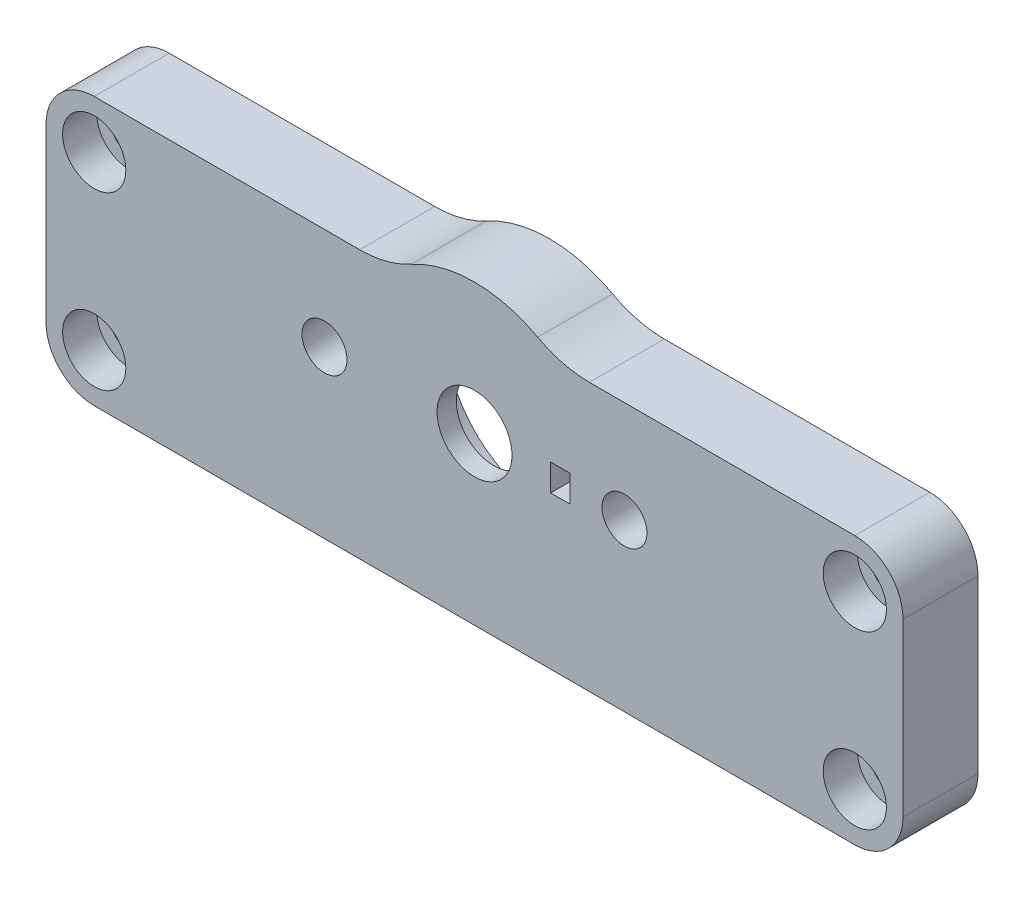
from build123d import *

# Parameters (mm, degrees)
SKETCH1_R           = 9.75
SKETCH1_R_2         = 1.65
BOSS_EXTRUDE1_DEPTH = 7
FILLET1_R           = 10
SKETCH2_R           = 9.75
SKETCH2_R_2         = 7.5
BOSS_EXTRUDE2_DEPTH = 2
SKETCH3_R           = 7.5
SKETCH3_R_2         = 3.5
BOSS_EXTRUDE3_DEPTH = 1.8
SKETCH4_W           = 1.8
SKETCH4_H           = 2.5
CUT_EXTRUDE1_DEPTH  = 2.5
SKETCH5_R           = 2.1
CUT_EXTRUDE2_DEPTH  = 3
SKETCH6_R           = 2.95
CUT_EXTRUDE3_DEPTH  = 3.2


with BuildPart() as part:
    # Sketch1 → Boss-Extrude1 (new body)
    with BuildSketch(Plane.XY):
        with BuildLine():
            Line((-35.5, 9.5), (-7.733854149, 9.5))
            ThreePointArc((-7.733854149, 9.5), (0, 12.25), (7.733854149, 9.5))
            Line((7.733854149, 9.5), (35.5, 9.5))
            ThreePointArc((35.5, 9.5), (38.681980515, 8.181980515), (40, 5))
            Line((40, 5), (40, -11))
            ThreePointArc((40, -11), (38.681980515, -14.181980515), (35.5, -15.5))
            Line((35.5, -15.5), (-35.5, -15.5))
            ThreePointArc((-35.5, -15.5), (-38.681980515, -14.181980515), (-40, -11))
            Line((-40, -11), (-40, 5))
            ThreePointArc((-40, 5), (-38.681980515, 8.181980515), (-35.5, 9.5))
        make_face()
        Circle(SKETCH1_R, mode=Mode.SUBTRACT)
        with Locations((-35.5, 5)):
            Circle(SKETCH1_R_2, mode=Mode.SUBTRACT)
        with Locations((35.5, 5)):
            Circle(SKETCH1_R_2, mode=Mode.SUBTRACT)
        with Locations((-35.5, -11)):
            Circle(SKETCH1_R_2, mode=Mode.SUBTRACT)
        with Locations((35.5, -11)):
            Circle(SKETCH1_R_2, mode=Mode.SUBTRACT)
    extrude(amount=BOSS_EXTRUDE1_DEPTH)

    # Fillet1
    fillet1_edges = [part.edges().sort_by_distance(p)[0] for p in [
        (7.733854149, 9.5, 3.5),
        (-7.733854149, 9.5, 3.5),
    ]]
    fillet(fillet1_edges, radius=FILLET1_R)

    # Sketch2 → Boss-Extrude2 (add)
    with BuildSketch(Plane.XY.offset(7)):
        Circle(SKETCH2_R)
        Circle(SKETCH2_R_2, mode=Mode.SUBTRACT)
    extrude(amount=-BOSS_EXTRUDE2_DEPTH)

    # Sketch3 → Boss-Extrude3 (add)
    with BuildSketch(Plane.XY.offset(7)):
        Circle(SKETCH3_R)
        Circle(SKETCH3_R_2, mode=Mode.SUBTRACT)
    extrude(amount=-BOSS_EXTRUDE3_DEPTH)

    # Sketch4 → Cut-Extrude1 (cut)
    with BuildSketch(Plane.XY.offset(7)):
        with Locations((8, 0)):
            Rectangle(SKETCH4_W, SKETCH4_H)
    extrude(amount=-CUT_EXTRUDE1_DEPTH, mode=Mode.SUBTRACT)

    # Sketch5 → Cut-Extrude2 (cut)
    with BuildSketch(Plane.XY.offset(7)):
        with Locations((-14, 0)):
            Circle(SKETCH5_R)
        with Locations((14, 0)):
            Circle(SKETCH5_R)
    extrude(amount=-CUT_EXTRUDE2_DEPTH, mode=Mode.SUBTRACT)

    # Sketch6 → Cut-Extrude3 (cut)
    with BuildSketch(Plane.XY.offset(7)):
        with Locations((-35.5, 5)):
            Circle(SKETCH6_R)
        with Locations((-35.5, -11)):
            Circle(SKETCH6_R)
        with Locations((35.5, -11)):
            Circle(SKETCH6_R)
        with Locations((35.5, 5)):
            Circle(SKETCH6_R)
    extrude(amount=-CUT_EXTRUDE3_DEPTH, mode=Mode.SUBTRACT)


solid = part.part
